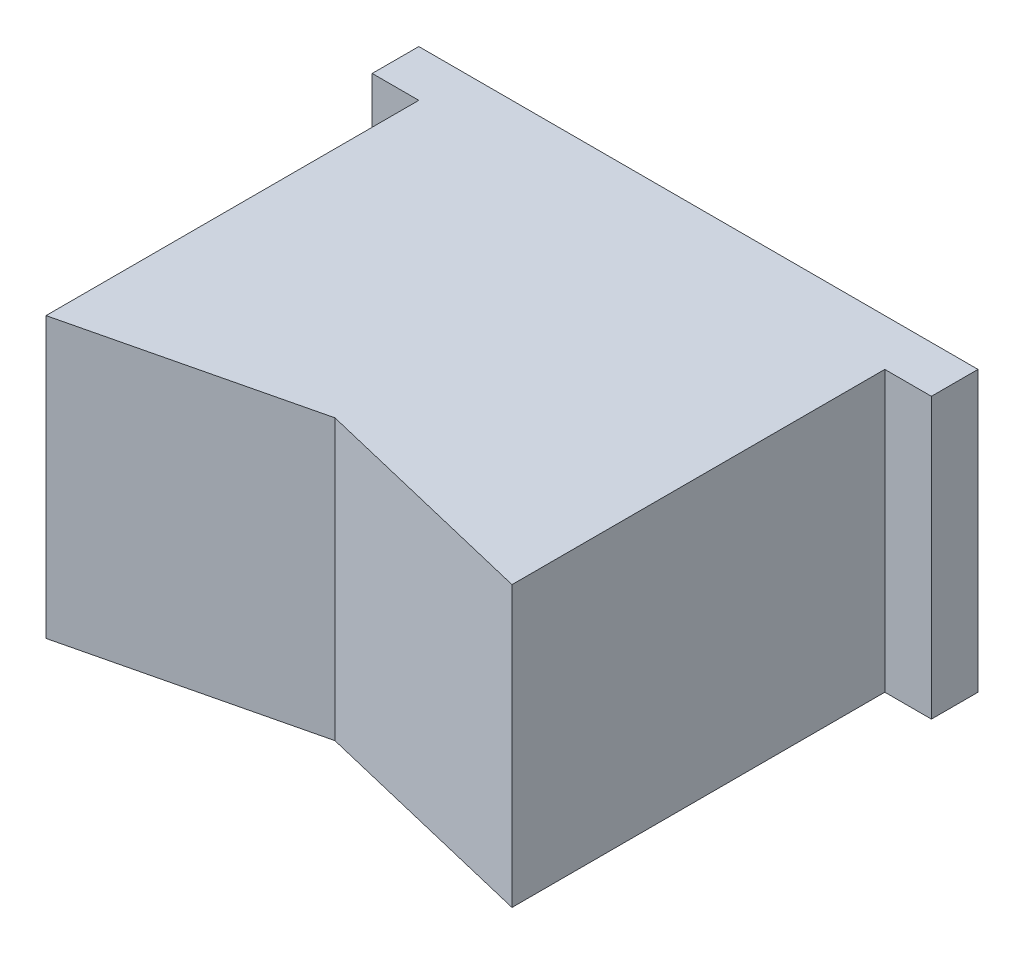
from build123d import *

# Parameters (mm, degrees)
CROQUIS1_W              = 30
CROQUIS1_H              = 15
SALIENTE_EXTRUIR1_DEPTH = 2.5
CROQUIS2_W              = 25
CROQUIS2_H              = 15
SALIENTE_EXTRUIR2_DEPTH = 20
CORTAR_EXTRUIR1_DEPTH   = 20
CROQUIS5_R              = 5
CORTAR_EXTRUIR3_DEPTH   = 4.6


with BuildPart() as part:
    # Croquis1 → Saliente-Extruir1 (new body)
    with BuildSketch(Plane.XY):
        Rectangle(CROQUIS1_W, CROQUIS1_H)
    extrude(amount=SALIENTE_EXTRUIR1_DEPTH)

    # Croquis2 → Saliente-Extruir2 (add)
    with BuildSketch(Plane.XY.offset(2.5)):
        Rectangle(CROQUIS2_W, CROQUIS2_H)
    extrude(amount=SALIENTE_EXTRUIR2_DEPTH)

    # Croquis4 → Cortar-Extruir1 (cut)
    with BuildSketch(Plane(origin=(0, 7.5, 0), x_dir=(1, 0, 0), z_dir=(0, 1, 0))):
        Polygon((-12.5, -22.5), (0, -19.5), (12.5, -22.5), align=None)
    extrude(amount=-CORTAR_EXTRUIR1_DEPTH, mode=Mode.SUBTRACT)

    # Croquis5 → Cortar-Extruir3 (cut)
    with BuildSketch(Plane(origin=(0, 0, 0), x_dir=(-1, 0, 0), z_dir=(0, 0, -1))):
        with Locations((-7, 0)):
            Circle(CROQUIS5_R)
        with Locations((7, 0)):
            Circle(CROQUIS5_R)
    extrude(amount=-CORTAR_EXTRUIR3_DEPTH, mode=Mode.SUBTRACT)


solid = part.part
